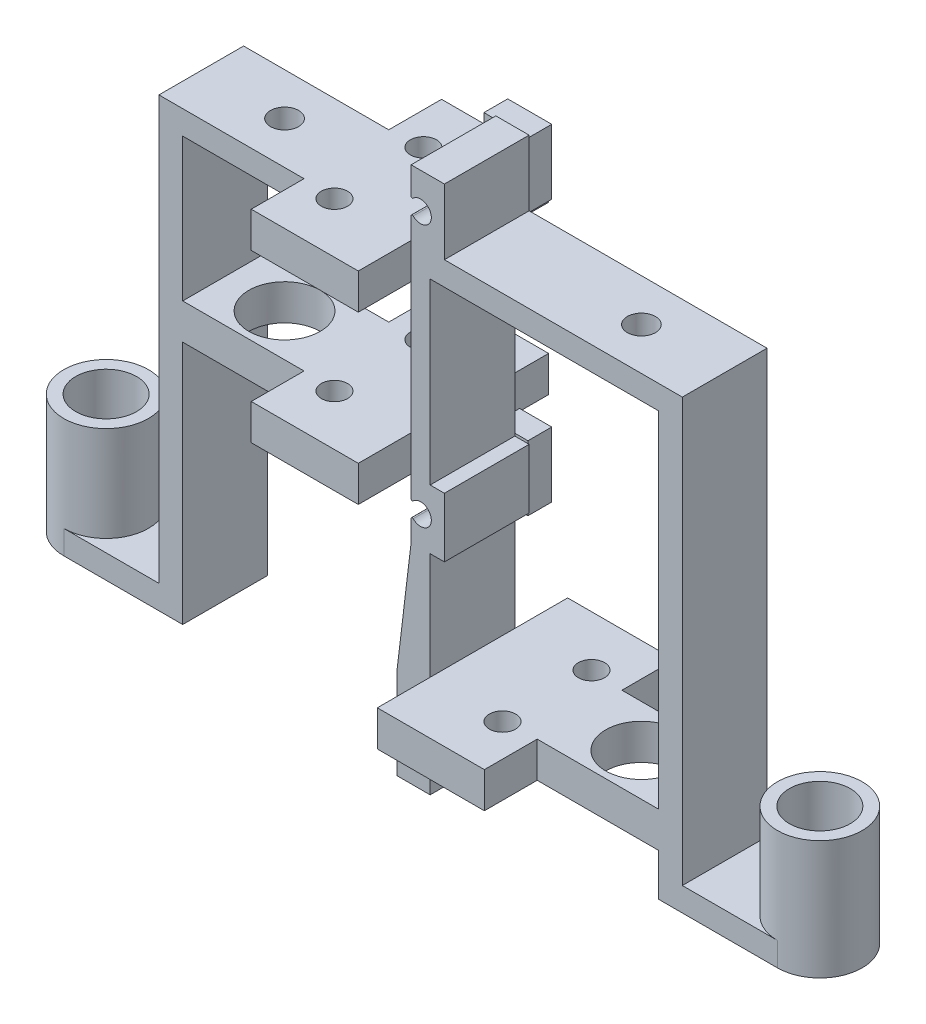
from build123d import *

# Parameters (mm, degrees)
SKETCH1_R                = 3.2512
BOSS_EXTRUDE1_DEPTH      = 12.7
CUT_EXTRUDE2_DEPTH       = 10.16
SKETCH3_W                = 25.4
SKETCH3_H                = 9.0424
CUT_EXTRUDE3_DEPTH       = 10.16
SKETCH4_W                = 2.54
SKETCH4_H                = 9.0424
BOSS_EXTRUDE2_DEPTH      = 45.160000016
SKETCH5_W                = 55.88
SKETCH5_H                = 9.0424
SKETCH5_R                = 1.5
BOSS_EXTRUDE3_DEPTH      = 2.54
SKETCH7_W                = 2.54
SKETCH7_H                = 9.0424
BOSS_EXTRUDE4_DEPTH      = 7
BOSS_EXTRUDE4_DEPTH_BACK = 50.24
SKETCH10_W               = 11.43
SKETCH10_H               = 20.32
SKETCH10_R               = 1.4
BOSS_EXTRUDE6_DEPTH      = 21.59
SKETCH11_W               = 1.524
SKETCH11_H               = 9.0424
CUT_EXTRUDE4_DEPTH       = 7
CUT_EXTRUDE5_DEPTH       = 7
SKETCH12_W               = 11.43
SKETCH12_H               = 20.32
SKETCH12_R               = 1.4
BOSS_EXTRUDE7_DEPTH      = 40.64
SKETCH13_W               = 11.43
SKETCH13_H               = 13.97
SKETCH13_H_2             = 36.83
CUT_EXTRUDE6_DEPTH       = 100.603737536
SKETCH15_W               = 9.0424
SKETCH15_H               = 3.81
BOSS_EXTRUDE8_DEPTH      = 12.954
SKETCH16_W               = 9.0424
SKETCH16_H               = 3.81
BOSS_EXTRUDE9_DEPTH      = 12.954
CUT_EXTRUDE7_DEPTH       = 99.608010651
CUT_EXTRUDE7_DEPTH_BACK  = 99.608010651
SKETCH18_W               = 3.556
SKETCH18_H               = 6.35
BOSS_EXTRUDE10_DEPTH     = 9.0424
CUT_EXTRUDE8_REACH       = 97.589
SKETCH21_R               = 3.81
SKETCH21_R_2             = 1.5
SKETCH19_R               = 1.143
CUT_EXTRUDE9_DEPTH       = 12.7
SKETCH22_W               = 1.524
SKETCH22_H               = 7.060000016
CUT_EXTRUDE10_DEPTH      = 99.608010651
CUT_EXTRUDE10_DEPTH_BACK = 99.608010651
FILLET1_R                = 0.127
SKETCH23_W               = 2.159
SKETCH23_H               = 4.4
CUT_EXTRUDE11_DEPTH      = 2.2712
CUT_EXTRUDE11_DEPTH_BACK = 0.5
SKETCH24_W               = 2.159
SKETCH24_H               = 4.4
SKETCH24_W_2             = 1.27
SKETCH24_H_2             = 6.94
SKETCH24_W_3             = 1.397
SKETCH24_H_3             = 0.32
SKETCH24_H_4             = 0.27
BOSS_EXTRUDE11_DEPTH     = 2.54
CUT_EXTRUDE13_DEPTH      = 100.018038057
CHAMFER1_SIZE            = 1.016


with BuildPart() as part:
    # Sketch1 → Boss-Extrude1 (new body)
    with BuildSketch(Plane(origin=(0, 0, 0), x_dir=(1, 0, 0), z_dir=(0, 1, 0))):
        with BuildLine():
            Line((0, 4.5212), (76.2, 4.5212))
            ThreePointArc((76.2, 4.5212), (80.7212, 0), (76.2, -4.5212))
            Line((76.2, -4.5212), (0, -4.5212))
            ThreePointArc((0, -4.5212), (-4.5212, 0), (0, 4.5212))
        make_face()
        with Locations(Location((0, 0, 0), (0, 0, 270))):
            Circle(SKETCH1_R, mode=Mode.SUBTRACT)
        with Locations(Location((76.2, 0, 0), (0, 0, 270))):
            Circle(SKETCH1_R, mode=Mode.SUBTRACT)
    extrude(amount=BOSS_EXTRUDE1_DEPTH)

    # Sketch2 → Cut-Extrude2 (cut)
    with BuildSketch(Plane(origin=(0, 12.7, 0), x_dir=(1, 0, 0), z_dir=(0, 1, 0))):
        with BuildLine():
            ThreePointArc((4.5212, 0), (3.196971179, -3.196971179), (0, -4.5212))
            Line((0, -4.5212), (76.2, -4.5212))
            ThreePointArc((76.2, -4.5212), (71.6788, 0), (76.2, 4.5212))
            Line((76.2, 4.5212), (0, 4.5212))
            ThreePointArc((0, 4.5212), (3.196971179, 3.196971179), (4.5212, 0))
        make_face()
    extrude(amount=-CUT_EXTRUDE2_DEPTH, mode=Mode.SUBTRACT)

    # Sketch3 → Cut-Extrude3 (cut)
    with BuildSketch(Plane(origin=(0, 2.54, 0), x_dir=(1, 0, 0), z_dir=(0, 1, 0))):
        with Locations((25.4, 0)):
            Rectangle(SKETCH3_W, SKETCH3_H)
        with Locations((50.8, 0)):
            Rectangle(SKETCH3_W, SKETCH3_H)
    extrude(amount=-CUT_EXTRUDE3_DEPTH, mode=Mode.SUBTRACT)


with BuildPart() as cut_extrude3_piece_1:
    # of the separate pieces the step leaves, piece 1, a body of its own (cut_extrude3_pieces)
    add(part.part.solids().sort_by_distance((12.7, 0, 4.5212))[0])



with BuildPart() as cut_extrude3_piece_2:
    # of the separate pieces the step leaves, piece 2, a body of its own (cut_extrude3_pieces)
    add(part.part.solids().sort_by_distance((76.2, 0, 4.5212))[0])


with BuildPart() as cut_extrude3_piece_1_1:
    add(cut_extrude3_piece_1.part)

    add(cut_extrude3_piece_2.part)  # Boss-Extrude2 merges Cut-Extrude3 piece 2
    # Sketch4 → Boss-Extrude2 (add)
    with BuildSketch(Plane(origin=(0, 2.54, 0), x_dir=(1, 0, 0), z_dir=(0, 1, 0))):
        with Locations((11.43, 0)):
            Rectangle(SKETCH4_W, SKETCH4_H)
        with Locations((64.77, 0)):
            Rectangle(SKETCH4_W, SKETCH4_H)
    extrude(amount=BOSS_EXTRUDE2_DEPTH)

    # Sketch5 → Boss-Extrude3 (add)
    with BuildSketch(Plane(origin=(0, 47.700000016, 0), x_dir=(1, 0, 0), z_dir=(0, 1, 0))):
        with Locations((38.1, 0)):
            Rectangle(SKETCH5_W, SKETCH5_H)
        with Locations(Location((19.05, 0, 0), (0, 0, 270))):
            Circle(SKETCH5_R, mode=Mode.SUBTRACT)
        with Locations(Location((57.15, 0, 0), (0, 0, 270))):
            Circle(SKETCH5_R, mode=Mode.SUBTRACT)
    extrude(amount=-BOSS_EXTRUDE3_DEPTH)

    # Sketch7 → Boss-Extrude4 (add, two sides)
    with BuildSketch(Plane(origin=(0, 47.700000016, 0), x_dir=(1, 0, 0), z_dir=(0, 1, 0))) as boss_extrude4_sk:
        with Locations((36.83, 0)):
            Rectangle(SKETCH7_W, SKETCH7_H)
        with Locations((39.37, 0)):
            Rectangle(SKETCH7_W, SKETCH7_H)
    extrude(amount=BOSS_EXTRUDE4_DEPTH)
    extrude(boss_extrude4_sk.sketch, amount=-BOSS_EXTRUDE4_DEPTH_BACK)

    # Sketch10 → Boss-Extrude6 (add)
    with BuildSketch(Plane(origin=(0, 47.700000016, 0), x_dir=(1, 0, 0), z_dir=(0, 1, 0))):
        with Locations((31.369, 0)):
            Rectangle(SKETCH10_W, SKETCH10_H)
        with Locations(Location((29.13, -4.75, 0), (0, 0, 270))):
            Circle(SKETCH10_R, mode=Mode.SUBTRACT)
        with Locations(Location((29.13, 4.75, 0), (0, 0, 270))):
            Circle(SKETCH10_R, mode=Mode.SUBTRACT)
    extrude(amount=-BOSS_EXTRUDE6_DEPTH)

    # Sketch11 → Cut-Extrude4 (cut)
    with BuildSketch(Plane(origin=(0, 47.700000016, 0), x_dir=(1, 0, 0), z_dir=(0, 1, 0))):
        Polygon((37.084, 4.5212), (37.084, 10.16), (25.654, 10.16), (25.654, 4.5212), (25.654, -4.5212), (25.654, -10.16), (37.084, -10.16), (37.084, -4.5212), (35.56, -4.5212), (35.56, 4.5212), align=None)
        with BuildLine():
            ThreePointArc((30.511177237, -4.5212), (30.525286374, -4.635213528), (30.53, -4.75))
            ThreePointArc((30.53, -4.75), (29.015213528, -6.145286374), (27.748822763, -4.5212))
            ThreePointArc((27.748822763, -4.5212), (29.13, -3.35), (30.511177237, -4.5212))
        make_face(mode=Mode.SUBTRACT)
        with BuildLine():
            ThreePointArc((27.748822763, 4.5212), (29.015213528, 6.145286374), (30.53, 4.75))
            ThreePointArc((30.53, 4.75), (30.525286374, 4.635213528), (30.511177237, 4.5212))
            ThreePointArc((30.511177237, 4.5212), (29.13, 3.35), (27.748822763, 4.5212))
        make_face(mode=Mode.SUBTRACT)
        with Locations((36.322, 0)):
            Rectangle(SKETCH11_W, SKETCH11_H)
    extrude(amount=CUT_EXTRUDE4_DEPTH, mode=Mode.SUBTRACT)

    # Sketch11_3 → Cut-Extrude5 (cut)
    with BuildSketch(Plane(origin=(0, 47.700000016, 0), x_dir=(1, 0, 0), z_dir=(0, 1, 0))):
        with BuildLine():
            ThreePointArc((30.511177237, -4.5212), (29.13, -6.15), (27.748822763, -4.5212))
            Line((27.748822763, -4.5212), (30.511177237, -4.5212))
        make_face()
        with BuildLine():
            ThreePointArc((30.511177237, 4.5212), (30.525286374, 4.635213528), (30.53, 4.75))
            ThreePointArc((30.53, 4.75), (29.015213528, 6.145286374), (27.748822763, 4.5212))
            Line((27.748822763, 4.5212), (30.511177237, 4.5212))
        make_face()
        with BuildLine():
            Line((30.511177237, 4.5212), (27.748822763, 4.5212))
            ThreePointArc((27.748822763, 4.5212), (29.13, 3.35), (30.511177237, 4.5212))
        make_face()
        with BuildLine():
            ThreePointArc((27.748822763, 4.5212), (29.13, 6.15), (30.511177237, 4.5212))
            Line((30.511177237, 4.5212), (27.748822763, 4.5212))
        make_face()
        with BuildLine():
            ThreePointArc((27.748822763, -4.5212), (29.015213528, -6.145286374), (30.53, -4.75))
            ThreePointArc((30.53, -4.75), (30.525286374, -4.635213528), (30.511177237, -4.5212))
            Line((30.511177237, -4.5212), (27.748822763, -4.5212))
        make_face()
        with BuildLine():
            Line((27.748822763, -4.5212), (30.511177237, -4.5212))
            ThreePointArc((30.511177237, -4.5212), (29.13, -3.35), (27.748822763, -4.5212))
        make_face()
    extrude(amount=-CUT_EXTRUDE5_DEPTH, mode=Mode.SUBTRACT)

    # Sketch12 → Boss-Extrude7 (add)
    with BuildSketch(Plane.XZ.offset(-45.160000016)):
        with Locations((44.831, 0)):
            Rectangle(SKETCH12_W, SKETCH12_H)
        with Locations(Location((47.07, -4.75, 0), (0, 0, 9.405959142))):
            Circle(SKETCH12_R, mode=Mode.SUBTRACT)
        with Locations(Location((47.07, 4.75, 0), (0, 0, 350.594040858))):
            Circle(SKETCH12_R, mode=Mode.SUBTRACT)
    extrude(amount=BOSS_EXTRUDE7_DEPTH)

    # Sketch13 → Cut-Extrude6 (cut, through all)
    with BuildSketch(Plane.XY.offset(10.16)):
        with Locations((31.369, 36.905000016)):
            Rectangle(SKETCH13_W, SKETCH13_H)
        with Locations((44.831, 26.745000016)):
            Rectangle(SKETCH13_W, SKETCH13_H_2)
    extrude(amount=-CUT_EXTRUDE6_DEPTH, mode=Mode.SUBTRACT)

    # Sketch15 → Boss-Extrude8 (add)
    with BuildSketch(Plane(origin=(12.7, 0, 0), x_dir=(0, 0, -1), z_dir=(1, 0, 0))):
        with Locations((0, 28.015000016)):
            Rectangle(SKETCH15_W, SKETCH15_H)
    extrude(amount=BOSS_EXTRUDE8_DEPTH)

    # Sketch16 → Boss-Extrude9 (add)
    with BuildSketch(Plane.ZY.offset(-63.5)):
        with Locations((0, 6.425000016)):
            Rectangle(SKETCH16_W, SKETCH16_H)
    extrude(amount=BOSS_EXTRUDE9_DEPTH)

    # Sketch17 → Cut-Extrude7 (cut, two sides)
    with BuildSketch(Plane.XY.offset(4.5212)) as cut_extrude7_sk:
        Polygon((37.084, 19.760000016), (37.084, 26.110000016), (35.56, 26.110000016), (35.56, 7.060000016), align=None)
    extrude(amount=CUT_EXTRUDE7_DEPTH, mode=Mode.SUBTRACT)
    extrude(cut_extrude7_sk.sketch, amount=-CUT_EXTRUDE7_DEPTH_BACK, mode=Mode.SUBTRACT)

    # Sketch18 → Boss-Extrude10 (add)
    with BuildSketch(Plane.XY.offset(4.5212)):
        with Locations((38.862, 22.935000016)):
            Rectangle(SKETCH18_W, SKETCH18_H)
    extrude(amount=-BOSS_EXTRUDE10_DEPTH)

    # Cut-Extrude8: up to this face of the body (flat: up to its plane)
    cut_extrude8_end = Plane(cut_extrude3_piece_1_1.part.faces().sort_by_distance((12.857978199, 45.160000016, 0))[0])
    # Sketch21 → Cut-Extrude8 (cut, up to the picked face)
    with BuildSketch(Plane.XZ.offset(-4.520000016), mode=Mode.PRIVATE) as cut_extrude8_sk1:
        with Locations(Location((57.15, 0, 0), (0, 0, 270))):
            Circle(SKETCH21_R)
        with Locations(Location((57.15, 0, 0), (0, 0, 90))):
            Circle(SKETCH21_R_2, mode=Mode.SUBTRACT)
    cut_extrude8_tool1 = split(extrude(cut_extrude8_sk1.sketch, amount=-CUT_EXTRUDE8_REACH, mode=Mode.PRIVATE), bisect_by=cut_extrude8_end, keep=Keep.BOTH, mode=Mode.PRIVATE)
    # Sketch21 → Cut-Extrude8 (cut, up to the picked face)
    with BuildSketch(Plane.XZ.offset(-4.520000016), mode=Mode.PRIVATE) as cut_extrude8_sk2:
        with Locations(Location((57.15, 0, 0), (0, 0, 90))):
            Circle(SKETCH21_R_2)
    cut_extrude8_tool2 = split(extrude(cut_extrude8_sk2.sketch, amount=-CUT_EXTRUDE8_REACH, mode=Mode.PRIVATE), bisect_by=cut_extrude8_end, keep=Keep.BOTH, mode=Mode.PRIVATE)
    # Sketch21 → Cut-Extrude8 (cut, up to the picked face)
    with BuildSketch(Plane.XZ.offset(-4.520000016), mode=Mode.PRIVATE) as cut_extrude8_sk3:
        with Locations(Location((19.05, 0, 0), (0, 0, 270))):
            Circle(SKETCH21_R)
        with Locations(Location((19.05, 0, 0), (0, 0, 90))):
            Circle(SKETCH21_R_2, mode=Mode.SUBTRACT)
    cut_extrude8_tool3 = split(extrude(cut_extrude8_sk3.sketch, amount=-CUT_EXTRUDE8_REACH, mode=Mode.PRIVATE), bisect_by=cut_extrude8_end, keep=Keep.BOTH, mode=Mode.PRIVATE)
    # Sketch21 → Cut-Extrude8 (cut, up to the picked face)
    with BuildSketch(Plane.XZ.offset(-4.520000016), mode=Mode.PRIVATE) as cut_extrude8_sk4:
        with Locations(Location((19.05, 0, 0), (0, 0, 90))):
            Circle(SKETCH21_R_2)
    cut_extrude8_tool4 = split(extrude(cut_extrude8_sk4.sketch, amount=-CUT_EXTRUDE8_REACH, mode=Mode.PRIVATE), bisect_by=cut_extrude8_end, keep=Keep.BOTH, mode=Mode.PRIVATE)
    add(cut_extrude8_tool1.solids().sort_by(Axis((57.15, 4.52, 3.702237), (0, 1, 0)))[0], mode=Mode.SUBTRACT)
    add(cut_extrude8_tool2.solids().sort_by(Axis((57.15, 4.52, 0), (0, 1, 0)))[0], mode=Mode.SUBTRACT)
    add(cut_extrude8_tool3.solids().sort_by(Axis((19.05, 4.52, 3.702237), (0, 1, 0)))[0], mode=Mode.SUBTRACT)
    add(cut_extrude8_tool4.solids().sort_by(Axis((19.05, 4.52, 0), (0, 1, 0)))[0], mode=Mode.SUBTRACT)

    # Sketch19 → Cut-Extrude9 (cut)
    with BuildSketch(Plane.XY.offset(4.5212)):
        with Locations((38.1, 50.900000016)):
            Circle(SKETCH19_R)
        with Locations((38.1, 1.320000016)):
            Circle(SKETCH19_R)
        with Locations((38.1, 22.910000016)):
            Circle(SKETCH19_R)
    extrude(amount=-CUT_EXTRUDE9_DEPTH, mode=Mode.SUBTRACT)

    # Sketch22 → Cut-Extrude10 (cut, two sides)
    with BuildSketch(Plane.XY.offset(4.5212)) as cut_extrude10_sk:
        with Locations((39.878, 0.990000008)):
            Rectangle(SKETCH22_W, SKETCH22_H)
    extrude(amount=CUT_EXTRUDE10_DEPTH, mode=Mode.SUBTRACT)
    extrude(cut_extrude10_sk.sketch, amount=-CUT_EXTRUDE10_DEPTH_BACK, mode=Mode.SUBTRACT)

    # Fillet1
    fillet1_edges = [cut_extrude3_piece_1_1.edges().sort_by_distance(p)[0] for p in [
        (37.084, 23.43363443, 0),
        (37.084, 22.386365602, 0),
        (37.084, 51.42363443, 0),
        (37.084, 50.376365602, 0),
        (39.116, 1.84363443, 0),
        (39.116, 0.796365602, 0),
    ]]
    fillet(fillet1_edges, radius=FILLET1_R)

    # Sketch23 → Cut-Extrude11 (cut, two sides)
    with BuildSketch(Plane(origin=(0, 0, -2.25), x_dir=(-1, 0, 0), z_dir=(0, 0, -1))) as cut_extrude11_sk:
        with Locations((-38.1635, 50.900000016)):
            Rectangle(SKETCH23_W, SKETCH23_H)
        with Locations((-38.1635, 22.910000016)):
            Rectangle(SKETCH23_W, SKETCH23_H)
        with Locations((-38.0365, 1.320000016)):
            Rectangle(SKETCH23_W, SKETCH23_H)
    extrude(amount=CUT_EXTRUDE11_DEPTH, mode=Mode.SUBTRACT)
    extrude(cut_extrude11_sk.sketch, amount=-CUT_EXTRUDE11_DEPTH_BACK, mode=Mode.SUBTRACT)

    # Sketch24 → Boss-Extrude11 (add)
    with BuildSketch(Plane(origin=(0, 0, -4.5212), x_dir=(-1, 0, 0), z_dir=(0, 0, -1))):
        Polygon((-40.513, 47.430000016), (-37.084, 47.430000016), (-37.084, 47.700000016), (-37.084, 48.700000016), (-39.243, 48.700000016), (-39.243, 53.100000016), (-37.084, 53.100000016), (-37.084, 54.370000016), (-40.513, 54.370000016), align=None)
        Polygon((-37.084, 47.700000016), (-37.084, 47.430000016), (-35.814, 47.430000016), (-35.814, 54.370000016), (-37.084, 54.370000016), (-37.084, 53.100000016), (-37.084, 48.700000016), align=None)
        with Locations((-38.1635, 50.900000016)):
            Rectangle(SKETCH24_W, SKETCH24_H)
        with Locations((-36.4106, 22.910000016)):
            Rectangle(SKETCH24_W_2, SKETCH24_H_2)
        Polygon((-37.084, 19.760000016), (-37.0456, 19.440000016), (-37.0456, 26.380000016), (-37.084, 26.380000016), (-37.084, 26.110000016), (-37.084, 25.110000016), (-39.243, 25.110000016), (-39.243, 20.710000016), (-37.084, 20.710000016), align=None)
        Polygon((-39.116, 19.440000016), (-37.0456, 19.440000016), (-37.084, 19.760000016), (-37.084, 20.710000016), (-39.243, 20.710000016), (-39.243, 25.110000016), (-37.084, 25.110000016), (-37.084, 26.110000016), (-37.084, 26.380000016), (-39.116, 26.380000016), (-39.116, 26.110000016), (-40.513, 26.110000016), (-40.513, 19.760000016), (-39.116, 19.760000016), align=None)
        with Locations((-39.8145, 19.600000016)):
            Rectangle(SKETCH24_W_3, SKETCH24_H_3)
        with Locations((-39.8145, 26.245000016)):
            Rectangle(SKETCH24_W_3, SKETCH24_H_4)
        Polygon((-39.116, 4.520000016), (-39.116, 4.790000016), (-40.386, 4.790000016), (-40.386, -2.149999984), (-39.116, -2.149999984), (-39.116, -0.879999984), (-39.116, 3.520000016), align=None)
        with Locations((-38.0365, 1.320000016)):
            Rectangle(SKETCH24_W, SKETCH24_H)
        Polygon((-35.687, 4.790000016), (-39.116, 4.790000016), (-39.116, 4.520000016), (-39.116, 3.520000016), (-36.957, 3.520000016), (-36.957, -0.879999984), (-39.116, -0.879999984), (-39.116, -2.149999984), (-35.687, -2.149999984), align=None)
    extrude(amount=BOSS_EXTRUDE11_DEPTH)

    # Sketch25 → Cut-Extrude13 (cut, through all)
    with BuildSketch(Plane(origin=(0, 0, -7.0612), x_dir=(-1, 0, 0), z_dir=(0, 0, -1))):
        with BuildLine():
            ThreePointArc((-38.9001, 2.136265285), (-39.243, 1.320000016), (-38.9001, 0.503734747))
            ThreePointArc((-38.9001, 0.503734747), (-37.657318004, 0.266206085), (-36.957, 1.320000016))
            ThreePointArc((-36.957, 1.320000016), (-37.657318004, 2.373793947), (-38.9001, 2.136265285))
        make_face()
        with BuildLine():
            ThreePointArc((-36.957, 22.910000016), (-37.046206069, 23.352682012), (-37.2999, 23.726265285))
            ThreePointArc((-37.2999, 23.726265285), (-39.243, 22.910000016), (-37.2999, 22.093734747))
            ThreePointArc((-37.2999, 22.093734747), (-37.046206069, 22.46731802), (-36.957, 22.910000016))
        make_face()
        with BuildLine():
            ThreePointArc((-36.957, 50.900000016), (-37.046206069, 51.342682012), (-37.2999, 51.716265285))
            ThreePointArc((-37.2999, 51.716265285), (-39.243, 50.900000016), (-37.2999, 50.083734747))
            ThreePointArc((-37.2999, 50.083734747), (-37.046206069, 50.45731802), (-36.957, 50.900000016))
        make_face()
    extrude(amount=-CUT_EXTRUDE13_DEPTH, mode=Mode.SUBTRACT)

    # Chamfer1
    chamfer1_edges = [cut_extrude3_piece_1_1.edges().sort_by_distance(p)[0] for p in [
        (39.243, 1.320000016, -7.0612),
        (38.9001, 23.726265285, -7.0612),
        (38.9001, 51.716265285, -7.0612),
    ]]
    chamfer(chamfer1_edges, length=CHAMFER1_SIZE)


solid = cut_extrude3_piece_1_1.part
